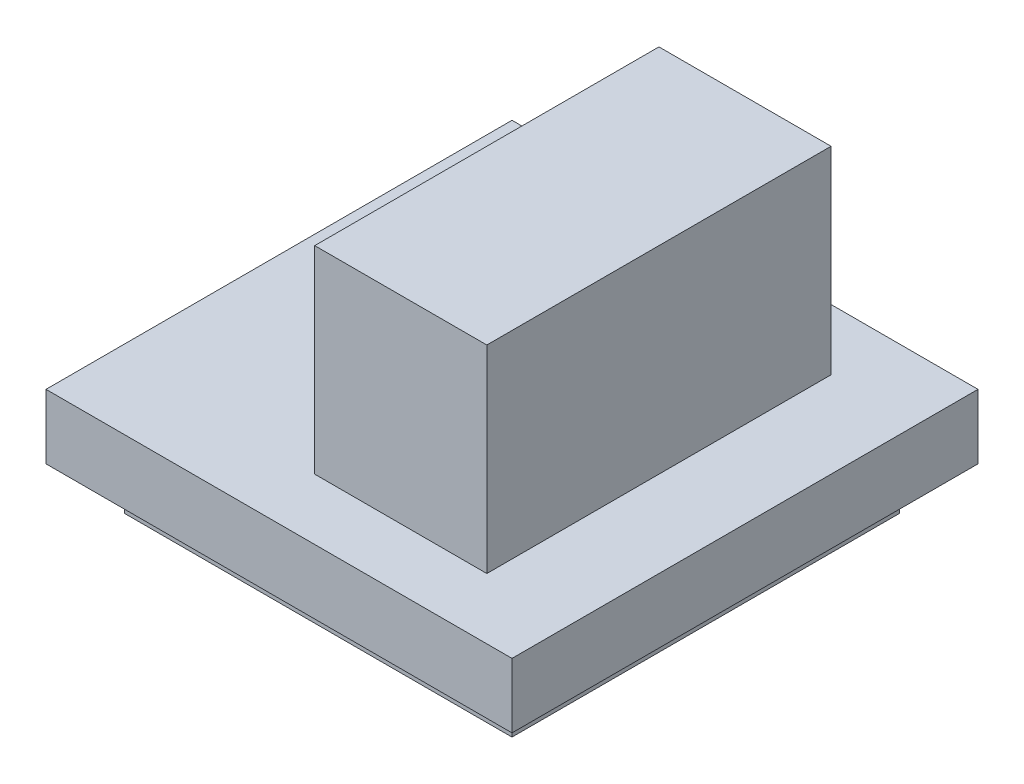
from build123d import *

# Parameters (mm, degrees)
SKETCH1_W      = 10.83
SKETCH1_H      = 10.83
EXTRUDE1_DEPTH = 1.5
SKETCH2_W      = 9
SKETCH2_H      = 9
EXTRUDE2_DEPTH = 1
SKETCH3_W      = 4
SKETCH3_H      = 8
EXTRUDE3_DEPTH = 4.6


with BuildPart() as part:
    # Sketch1 → Extrude1 (new body)
    with BuildSketch(Plane(origin=(0, 0, 0), x_dir=(1, 0, 0), z_dir=(0, 1, 0))):
        Rectangle(SKETCH1_W, SKETCH1_H)
    extrude(amount=EXTRUDE1_DEPTH)

    # Sketch2 → Extrude2 (add)
    with BuildSketch(Plane.XZ):
        Rectangle(SKETCH2_W, SKETCH2_H)
    extrude(amount=EXTRUDE2_DEPTH)

    # Sketch3 → Extrude3 (add)
    with BuildSketch(Plane(origin=(0, 1.5, 0), x_dir=(1, 0, 0), z_dir=(0, 1, 0))):
        with Locations((1.415, 0)):
            Rectangle(SKETCH3_W, SKETCH3_H)
    extrude(amount=EXTRUDE3_DEPTH)


solid = part.part
